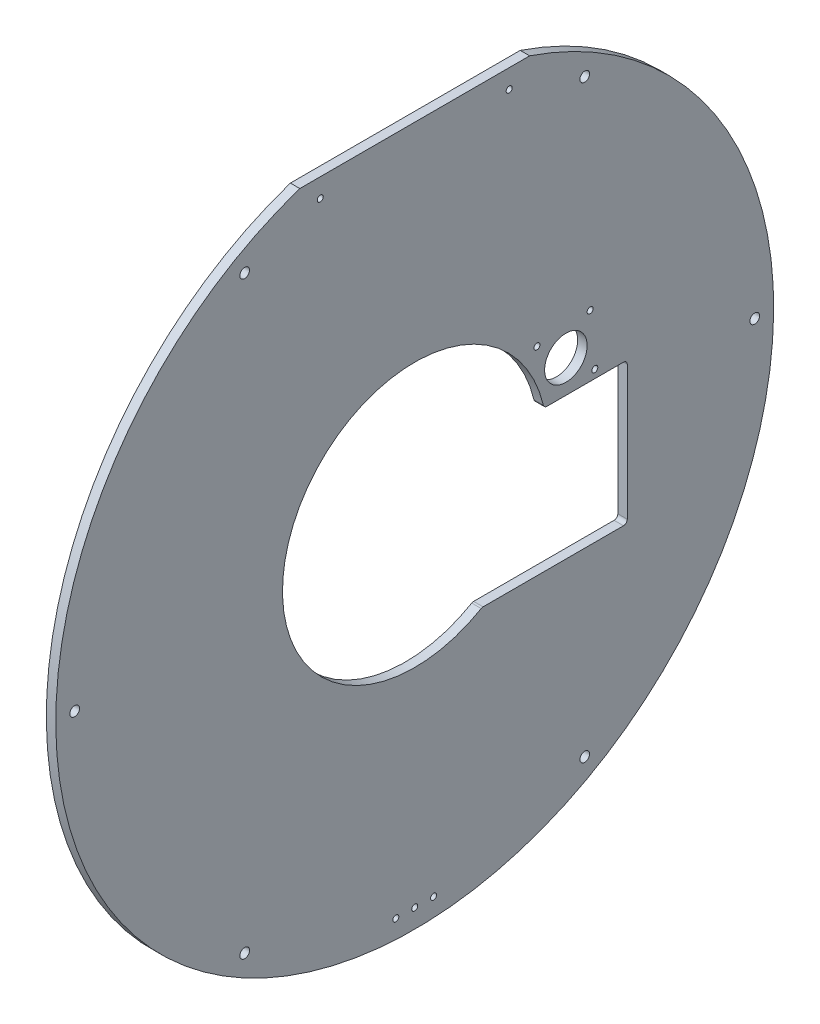
from build123d import *

# Parameters (mm, degrees)
SKETCH1_R           = 3.2639
SKETCH1_R_2         = 2.0193
SKETCH1_R_3         = 14.2875
BOSS_EXTRUDE1_DEPTH = 6.35
FILLET1_R           = 2.54


with BuildPart() as part:
    # Sketch1 → Boss-Extrude1 (new body)
    with BuildSketch(Plane(origin=(0, 0, 0), x_dir=(0, 0, -1), z_dir=(1, 0, 0))):
        with BuildLine():
            Line((77.251084135, 228.6), (-77.251084135, 228.6))
            ThreePointArc((-77.251084135, 228.6), (0, -241.3), (77.251084135, 228.6))
        make_face()
        with Locations((-114.3, -197.973407305)):
            Circle(SKETCH1_R, mode=Mode.SUBTRACT)
        with Locations((-12.7, -228.6)):
            Circle(SKETCH1_R_2, mode=Mode.SUBTRACT)
        with Locations((0, -228.6)):
            Circle(SKETCH1_R_2, mode=Mode.SUBTRACT)
        with Locations((12.7, -228.6)):
            Circle(SKETCH1_R_2, mode=Mode.SUBTRACT)
        with Locations((114.3, -197.973407305)):
            Circle(SKETCH1_R, mode=Mode.SUBTRACT)
        with Locations((228.6, 0)):
            Circle(SKETCH1_R, mode=Mode.SUBTRACT)
        with Locations((-228.6, 0)):
            Circle(SKETCH1_R, mode=Mode.SUBTRACT)
        with Locations((-114.3, 197.973407305)):
            Circle(SKETCH1_R, mode=Mode.SUBTRACT)
        with Locations((-63.5, 215.9)):
            Circle(SKETCH1_R_2, mode=Mode.SUBTRACT)
        with BuildLine():
            Line((142.875, -76.522457682), (45.249568731, -76.522457682))
            ThreePointArc((45.249568731, -76.522457682), (-81.451531518, 35.6210333), (86.905058303, 18.727542318))
            Line((86.905058303, 18.727542318), (142.875, 18.727542318))
            Line((142.875, 18.727542318), (142.875, -76.522457682))
        make_face(mode=Mode.SUBTRACT)
        with Locations((82.142471145, 56.966805286)):
            Circle(SKETCH1_R_2, mode=Mode.SUBTRACT)
        with Locations((101.6, 40.64)):
            Circle(SKETCH1_R_3, mode=Mode.SUBTRACT)
        with Locations((117.926805286, 60.097528855)):
            Circle(SKETCH1_R_2, mode=Mode.SUBTRACT)
        with Locations((121.057528855, 24.313194714)):
            Circle(SKETCH1_R_2, mode=Mode.SUBTRACT)
        with Locations((114.3, 197.973407305)):
            Circle(SKETCH1_R, mode=Mode.SUBTRACT)
        with Locations((63.5, 215.9)):
            Circle(SKETCH1_R_2, mode=Mode.SUBTRACT)
    extrude(amount=BOSS_EXTRUDE1_DEPTH)

    # Fillet1
    fillet1_edges = [part.edges().sort_by_distance(p)[0] for p in [
        (3.175, -76.522457682, -45.249568731),
        (3.175, -76.522457682, -142.875),
        (3.175, 18.727542318, -142.875),
        (3.175, 18.727542318, -86.905058303),
    ]]
    fillet(fillet1_edges, radius=FILLET1_R)


solid = part.part
